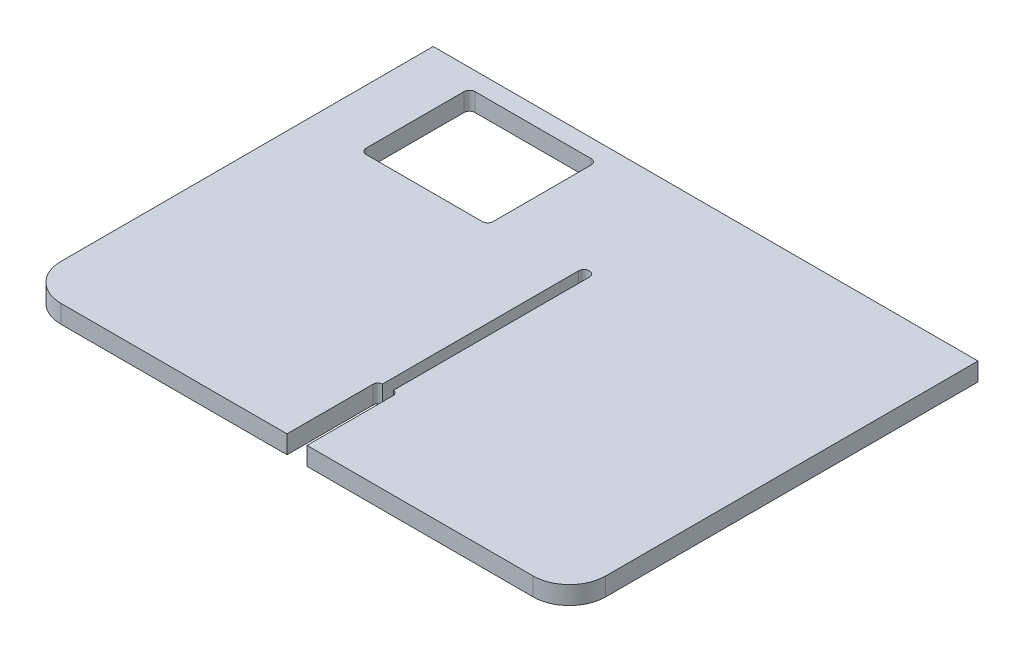
from build123d import *

# Parameters (mm, degrees)
LINEAR_AUSTRAGEN1_DEPTH         = 10
VERRUNDUNG1_R                   = 20
VERRUNDUNG1_OF_SPIEGELN2_R      = 20
SKIZZE3_W                       = 70
SKIZZE3_H                       = 60
SCHNITT_LINEAR_AUSTRAGEN1_DEPTH = 11
VERRUNDUNG2_R                   = 3
SCHNITT_LINEAR_AUSTRAGEN2_DEPTH = 10


with BuildPart() as part:
    # Skizze1 → Linear austragen1 (new body)
    with BuildSketch(Plane(origin=(0, 0, 0), x_dir=(1, 0, 0), z_dir=(0, 1, 0))):
        Polygon((150, 75), (150, 150), (0, 150), (0, 75), (0, -75), (150, -75), align=None)
    linear_austragen1 = extrude(amount=LINEAR_AUSTRAGEN1_DEPTH)

    # Verrundung1
    verrundung1_edges = [part.edges().sort_by_distance(p)[0] for p in [
        (150, 5, 75),
    ]]
    fillet(verrundung1_edges, radius=VERRUNDUNG1_R)

    # Spiegeln2: Linear austragen1 across plane
    add(linear_austragen1.mirror(Plane(origin=(0, 10, -150), x_dir=(0, 0, 1), z_dir=(1, 0, 0))))

    # Verrundung1 of Spiegeln2
    verrundung1_of_spiegeln2_edges = [part.edges().sort_by_distance(p)[0] for p in [
        (-150, 5, 75),
    ]]
    fillet(verrundung1_of_spiegeln2_edges, radius=VERRUNDUNG1_OF_SPIEGELN2_R)

    # Skizze3 → Schnitt-Linear austragen1 (cut, through all)
    with BuildSketch(Plane(origin=(0, 0, 0), x_dir=(-1, 0, 0), z_dir=(0, 1, 0))):
        with Locations((85, -110)):
            Rectangle(SKIZZE3_W, SKIZZE3_H)
    extrude(amount=SCHNITT_LINEAR_AUSTRAGEN1_DEPTH, mode=Mode.SUBTRACT)

    # Verrundung2
    verrundung2_edges = [part.edges().sort_by_distance(p)[0] for p in [
        (-120, 5, -140),
        (-120, 5, -80),
        (-50, 5, -80),
        (-50, 5, -140),
    ]]
    fillet(verrundung2_edges, radius=VERRUNDUNG2_R)

    # Skizze4 → Schnitt-Linear austragen2 (cut)
    with BuildSketch(Plane.XZ):
        with BuildLine():
            Line((-3, 25), (-3, -83))
            ThreePointArc((-3, -83), (0, -86), (3, -83))
            Line((3, -83), (3, 25))
            ThreePointArc((3, 25), (4.75069059, 25.725159786), (5.475850376, 27.475850376))
            Line((5.475850376, 27.475850376), (5.475850376, 75))
            Line((5.475850376, 75), (-5.524149624, 75))
            Line((-5.524149624, 75), (-5.524149624, 27.524149624))
            ThreePointArc((-5.524149624, 27.524149624), (-4.784843316, 25.739306308), (-3, 25))
        make_face()
    extrude(amount=-SCHNITT_LINEAR_AUSTRAGEN2_DEPTH, mode=Mode.SUBTRACT)


solid = part.part
